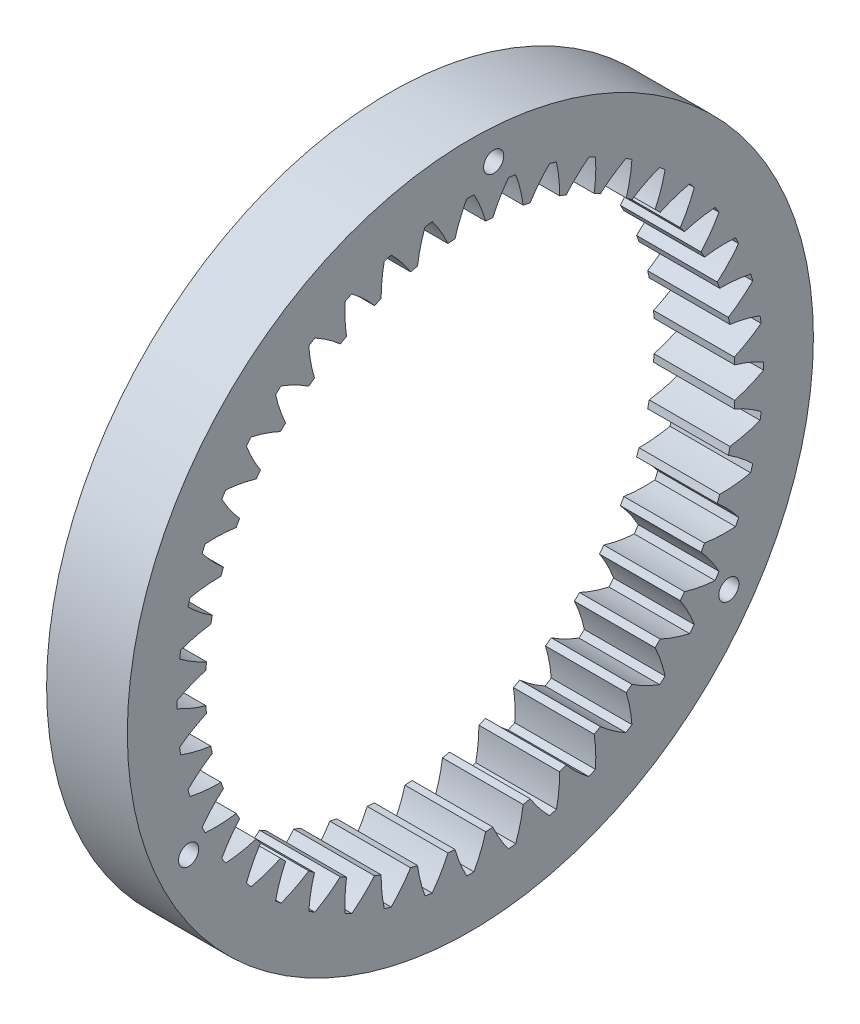
from build123d import *

# Parameters (mm, degrees)
BASPROSKE_W                     = 8
BASPROSKE_H                     = 7.75
TOOTHCUT_DEPTH                  = 49.744230428
TEETHCUTS_COUNT                 = 44
TEETHCUTS_ANGLE                 = 351.818181818
SCHNITT_LINEAR_AUSTRAGEN1_REACH = 50.744
SKIZZE1_R                       = 1
KREISMUSTER1_COUNT              = 3


with BuildPart() as part:
    # BasProSke → Base-Revolve (revolve)
    with BuildSketch(Plane(origin=(0, 0, 0), x_dir=(1, 0, 0), z_dir=(0, 1, 0))):
        with Locations((4, 30.125)):
            Rectangle(BASPROSKE_W, BASPROSKE_H)
    revolve(axis=Axis((-10, 0, 0), (1, 0, 0)))

    # TooCutSke → ToothCut (cut, through all)
    with BuildSketch(Plane(origin=(0, 0, 0), x_dir=(0, 0, -1), z_dir=(1, 0, 0))):
        with BuildLine():
            ThreePointArc((1.527586196, 26.180071153), (1.024085746, 27.653885232), (0.357145906, 29.061305529))
            ThreePointArc((0.357145906, 29.061305529), (0, 29.0635), (-0.357145906, 29.061305529))
            ThreePointArc((-0.357145906, 29.061305529), (-1.024085746, 27.653885232), (-1.527586196, 26.180071153))
            ThreePointArc((-1.527586196, 26.180071153), (0, 26.2246), (1.527586196, 26.180071153))
        make_face()
    toothcut = extrude(amount=TOOTHCUT_DEPTH, mode=Mode.SUBTRACT)

    # TeethCuts: ToothCut ×44 about axis
    teethcuts_axis = Axis((-10, 0, 0), (1, 0, 0))
    for i in range(1, TEETHCUTS_COUNT):
        add(toothcut.rotate(teethcuts_axis, i * TEETHCUTS_ANGLE / (TEETHCUTS_COUNT - 1)), mode=Mode.SUBTRACT)

    # Skizze1 → Schnitt-Linear austragen1 (cut, up to next)
    with BuildSketch(Plane(origin=(8, 0, 0), x_dir=(0, 0, -1), z_dir=(1, 0, 0)), mode=Mode.PRIVATE) as schnitt_linear_austragen1_sk1:
        with Locations((2.310681633, 30.913763122)):
            Circle(SKIZZE1_R)
    schnitt_linear_austragen1_tool1 = extrude(schnitt_linear_austragen1_sk1.sketch, amount=-SCHNITT_LINEAR_AUSTRAGEN1_REACH, mode=Mode.PRIVATE) & part.part
    schnitt_linear_austragen1 = schnitt_linear_austragen1_tool1.solids().sort_by_distance((8, 30.913763, -2.310682))[0]
    add(schnitt_linear_austragen1, mode=Mode.SUBTRACT)

    # Kreismuster1: Schnitt-Linear austragen1 ×3 about axis
    kreismuster1_axis = Axis((-10, 0, 0), (-1, 0, 0))
    for i in range(1, KREISMUSTER1_COUNT):
        add(schnitt_linear_austragen1.rotate(kreismuster1_axis, i * 360 / KREISMUSTER1_COUNT), mode=Mode.SUBTRACT)


solid = part.part
